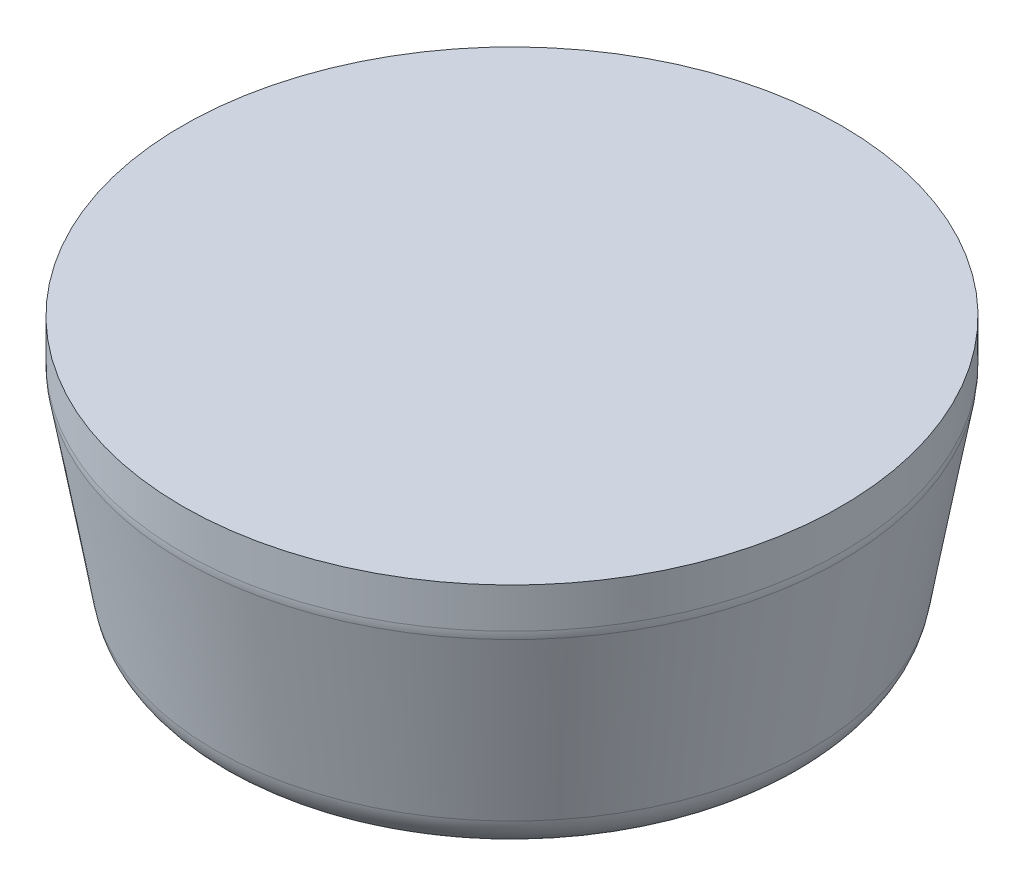
from build123d import *

# Parameters (mm, degrees)
SKETCH2_R           = 7.5
BOSS_EXTRUDE1_DEPTH = 5
BOSS_EXTRUDE1_TAPER = 10
SKETCH3_R           = 7.5
BOSS_EXTRUDE2_DEPTH = 1
FILLET1_R           = 1


with BuildPart() as part:
    # Sketch2 → Boss-Extrude1 (new body)
    with BuildSketch(Plane(origin=(0, 0, 0), x_dir=(1, 0, 0), z_dir=(0, 1, 0))):
        Circle(SKETCH2_R)
    extrude(amount=-BOSS_EXTRUDE1_DEPTH, taper=BOSS_EXTRUDE1_TAPER)

    # Sketch3 → Boss-Extrude2 (add)
    with BuildSketch(Plane(origin=(0, 0, 0), x_dir=(1, 0, 0), z_dir=(0, 1, 0))):
        Circle(SKETCH3_R)
    extrude(amount=BOSS_EXTRUDE2_DEPTH)

    # Fillet1
    fillet1_edges = [part.edges().sort_by_distance(p)[0] for p in [
        (-7.5, 0, 0),
        (-6.618365096, -5, 0),
    ]]
    fillet(fillet1_edges, radius=FILLET1_R)


solid = part.part
